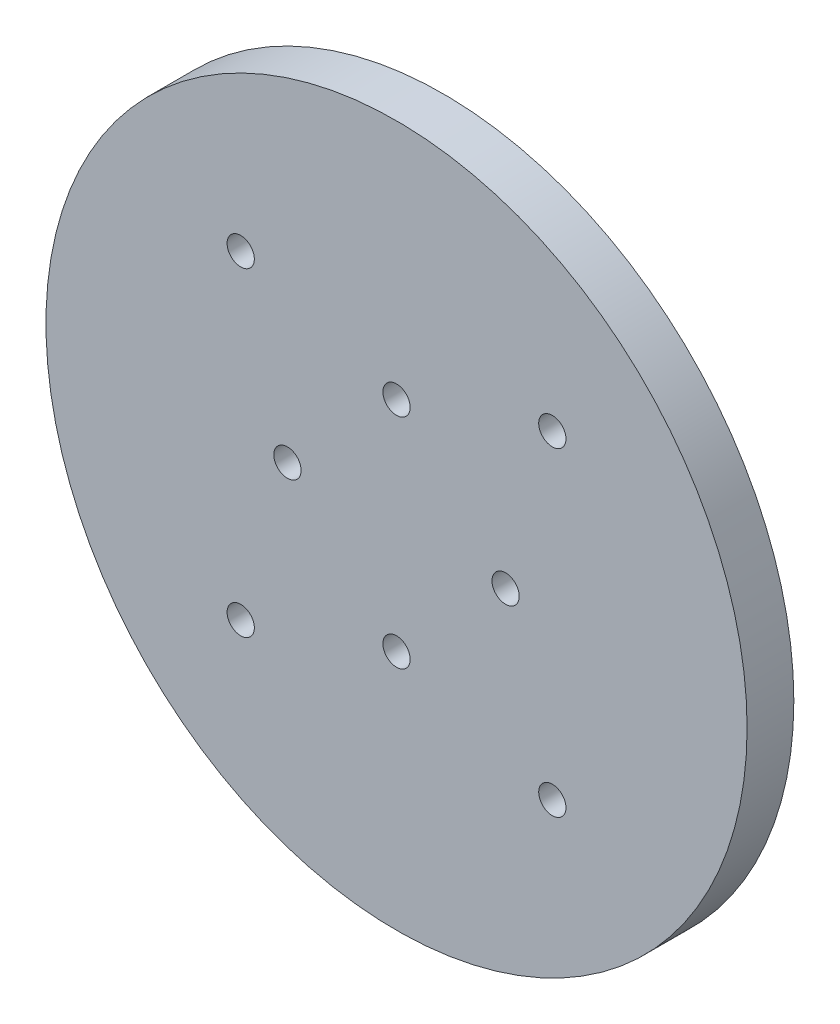
from build123d import *

# Parameters (mm, degrees)
SKETCH1_R               = 45
BOSS_EXTRUDE1_DEPTH     = 6
SKETCH2_R               = 22
BOSS_EXTRUDE2_DEPTH     = 6
SKETCH3_R               = 20.1
BOSS_EXTRUDE3_DEPTH     = 4.7
SKETCH4_R               = 18.1
CUT_EXTRUDE1_DEPTH      = 11
SKETCH5_R               = 1.75
CUT_EXTRUDE2_DEPTH      = 6.7
SKETCH6_R               = 1.75
CUT_EXTRUDE3_DEPTH      = 12
CUT_EXTRUDE3_DEPTH_BACK = 6.7
SKETCH7_R               = 2.9
CUT_EXTRUDE5_DEPTH      = 3.3


with BuildPart() as part:
    # Sketch1 → Boss-Extrude1 (new body)
    with BuildSketch(Plane.XY):
        Circle(SKETCH1_R)
    extrude(amount=BOSS_EXTRUDE1_DEPTH)

    # Sketch2 → Boss-Extrude2 (add)
    with BuildSketch(Plane(origin=(0, 0, 0), x_dir=(-1, 0, 0), z_dir=(0, 0, -1))):
        Circle(SKETCH2_R)
    extrude(amount=BOSS_EXTRUDE2_DEPTH)

    # Sketch3 → Boss-Extrude3 (add)
    with BuildSketch(Plane(origin=(0, 0, -6), x_dir=(-1, 0, 0), z_dir=(0, 0, -1))):
        Circle(SKETCH3_R)
    extrude(amount=BOSS_EXTRUDE3_DEPTH)

    # Sketch4 → Cut-Extrude1 (cut)
    with BuildSketch(Plane(origin=(0, 0, -10.7), x_dir=(-1, 0, 0), z_dir=(0, 0, -1))):
        Circle(SKETCH4_R)
    extrude(amount=-CUT_EXTRUDE1_DEPTH, mode=Mode.SUBTRACT)

    # Sketch5 → Cut-Extrude2 (cut, through all)
    with BuildSketch(Plane(origin=(0, 0, 0.3), x_dir=(-1, 0, 0), z_dir=(0, 0, -1))):
        with Locations((14, 0)):
            Circle(SKETCH5_R)
        with Locations((0, -14)):
            Circle(SKETCH5_R)
        with Locations((-14, 0)):
            Circle(SKETCH5_R)
        with Locations((0, 14)):
            Circle(SKETCH5_R)
    extrude(amount=-CUT_EXTRUDE2_DEPTH, mode=Mode.SUBTRACT)

    # Sketch6 → Cut-Extrude3 (cut, two sides)
    with BuildSketch(Plane(origin=(0, 0, 0.3), x_dir=(-1, 0, 0), z_dir=(0, 0, -1))) as cut_extrude3_sk:
        with Locations((19.999991423, -20.5)):
            Circle(SKETCH6_R)
        with Locations((-19.999991423, 20.5)):
            Circle(SKETCH6_R)
        with Locations((-19.999991423, -20.5)):
            Circle(SKETCH6_R)
        with Locations((19.999991423, 20.5)):
            Circle(SKETCH6_R)
    extrude(amount=CUT_EXTRUDE3_DEPTH, mode=Mode.SUBTRACT)
    extrude(cut_extrude3_sk.sketch, amount=-CUT_EXTRUDE3_DEPTH_BACK, mode=Mode.SUBTRACT)

    # Sketch7 → Cut-Extrude5 (cut)
    with BuildSketch(Plane.XY):
        with Locations((19.999991423, 20.5)):
            Circle(SKETCH7_R)
        with Locations((-19.999991423, 20.5)):
            Circle(SKETCH7_R)
        with Locations((-19.999991423, -20.5)):
            Circle(SKETCH7_R)
        with Locations((19.999991423, -20.5)):
            Circle(SKETCH7_R)
    extrude(amount=CUT_EXTRUDE5_DEPTH, mode=Mode.SUBTRACT)


solid = part.part
